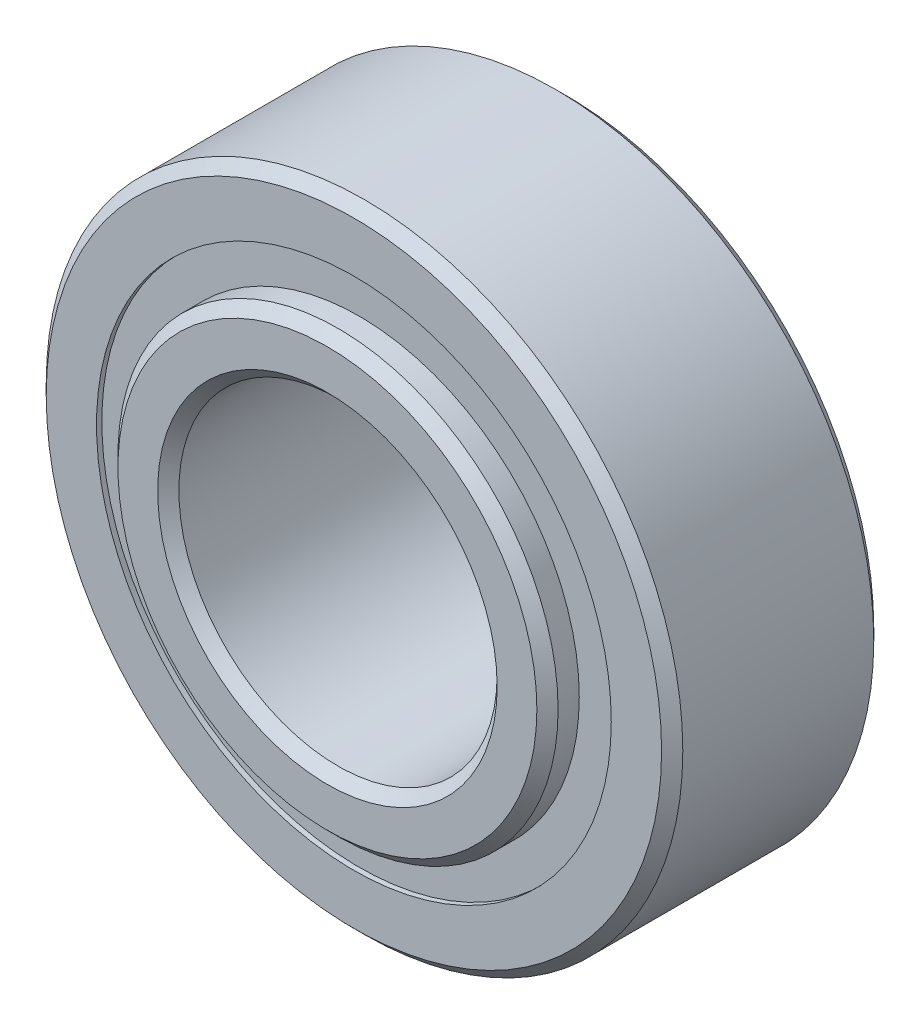
from build123d import *

# Parameters (mm, degrees)
CIRPATTERN1_COUNT = 12
SKETCH5_W         = 0.749364756
SKETCH5_H         = 0.558241758


with BuildPart() as part:
    # Sketch1 → Revolve1 (revolve)
    with BuildSketch(Plane(origin=(0, 0, 0), x_dir=(0, 0, -1), z_dir=(1, 0, 0))):
        with BuildLine():
            Line((1.42875, 4.7625), (-1.42875, 4.7625))
            Line((-1.42875, 4.7625), (-1.5875, 4.60375))
            Line((-1.5875, 4.60375), (-1.5875, 3.850995879))
            Line((-1.5875, 3.850995879), (-0.705555556, 3.850995879))
            ThreePointArc((-0.705555556, 3.850995879), (0, 4.330635244), (0.705555556, 3.850995879))
            Line((0.705555556, 3.850995879), (1.5875, 3.850995879))
            Line((1.5875, 3.850995879), (1.5875, 4.60375))
            Line((1.5875, 4.60375), (1.42875, 4.7625))
        make_face()
    revolve(axis=Axis((0, 0, 1.5875), (0, 0, -1)))


with BuildPart() as body_2:
    # Sketch3 → Revolve3 (revolve)
    with BuildSketch(Plane(origin=(0, 0, 0), x_dir=(0, 0, -1), z_dir=(1, 0, 0))):
        with BuildLine():
            Line((-1.98374, 2.54), (-1.98374, 3.134004121))
            Line((-1.98374, 3.134004121), (-1.82499, 3.292754121))
            Line((-1.82499, 3.292754121), (-0.705555556, 3.292754121))
            ThreePointArc((-0.705555556, 3.292754121), (0, 2.813114756), (0.705555556, 3.292754121))
            Line((0.705555556, 3.292754121), (1.82499, 3.292754121))
            Line((1.82499, 3.292754121), (1.98374, 3.134004121))
            Line((1.98374, 3.134004121), (1.98374, 2.54))
            Line((1.98374, 2.54), (1.82499, 2.38125))
            Line((1.82499, 2.38125), (-1.82499, 2.38125))
            Line((-1.82499, 2.38125), (-1.98374, 2.54))
        make_face()
    revolve(axis=Axis((0, 0, 1.5875), (0, 0, -1)))


with BuildPart() as body_3:
    # Sketch4 → Revolve4 (revolve)
    with BuildSketch(Plane(origin=(0, 0, 0), x_dir=(0, 0, -1), z_dir=(1, 0, 0))):
        with BuildLine():
            Line((-0.758760244, 3.571875), (0.758760244, 3.571875))
            ThreePointArc((0.758760244, 3.571875), (0, 4.330635244), (-0.758760244, 3.571875))
        make_face()
    revolve(axis=Axis((0, 3.571875, 0.758760244), (0, 0, -1)))


with BuildPart() as cirpattern1_1:
    # CirPattern1: pattern copy
    add(body_3.part.rotate(Axis((0, 0, -1.5875), (0, 0, 1)), 1 * 360 / CIRPATTERN1_COUNT))


with BuildPart() as cirpattern1_2:
    # CirPattern1: pattern copy
    add(body_3.part.rotate(Axis((0, 0, -1.5875), (0, 0, 1)), 2 * 360 / CIRPATTERN1_COUNT))


with BuildPart() as cirpattern1_3:
    # CirPattern1: pattern copy
    add(body_3.part.rotate(Axis((0, 0, -1.5875), (0, 0, 1)), 3 * 360 / CIRPATTERN1_COUNT))


with BuildPart() as cirpattern1_4:
    # CirPattern1: pattern copy
    add(body_3.part.rotate(Axis((0, 0, -1.5875), (0, 0, 1)), 4 * 360 / CIRPATTERN1_COUNT))


with BuildPart() as cirpattern1_5:
    # CirPattern1: pattern copy
    add(body_3.part.rotate(Axis((0, 0, -1.5875), (0, 0, 1)), 5 * 360 / CIRPATTERN1_COUNT))


with BuildPart() as cirpattern1_6:
    # CirPattern1: pattern copy
    add(body_3.part.rotate(Axis((0, 0, -1.5875), (0, 0, 1)), 6 * 360 / CIRPATTERN1_COUNT))


with BuildPart() as cirpattern1_7:
    # CirPattern1: pattern copy
    add(body_3.part.rotate(Axis((0, 0, -1.5875), (0, 0, 1)), 7 * 360 / CIRPATTERN1_COUNT))


with BuildPart() as cirpattern1_8:
    # CirPattern1: pattern copy
    add(body_3.part.rotate(Axis((0, 0, -1.5875), (0, 0, 1)), 8 * 360 / CIRPATTERN1_COUNT))


with BuildPart() as cirpattern1_9:
    # CirPattern1: pattern copy
    add(body_3.part.rotate(Axis((0, 0, -1.5875), (0, 0, 1)), 9 * 360 / CIRPATTERN1_COUNT))


with BuildPart() as cirpattern1_10:
    # CirPattern1: pattern copy
    add(body_3.part.rotate(Axis((0, 0, -1.5875), (0, 0, 1)), 10 * 360 / CIRPATTERN1_COUNT))


with BuildPart() as cirpattern1_11:
    # CirPattern1: pattern copy
    add(body_3.part.rotate(Axis((0, 0, -1.5875), (0, 0, 1)), 11 * 360 / CIRPATTERN1_COUNT))


with BuildPart() as body_15:
    # Sketch5 → Revolve5 (revolve)
    with BuildSketch(Plane(origin=(0, 0, 0), x_dir=(0, 0, -1), z_dir=(1, 0, 0))):
        with Locations((-1.133442622, 3.571875)):
            Rectangle(SKETCH5_W, SKETCH5_H)
        with Locations((1.133442622, 3.571875)):
            Rectangle(SKETCH5_W, SKETCH5_H)
    revolve(axis=Axis((0, 0, 1.5875), (0, 0, -1)))


solid = Compound([part.part, body_2.part, body_3.part, cirpattern1_1.part, cirpattern1_2.part, cirpattern1_3.part, cirpattern1_4.part, cirpattern1_5.part, cirpattern1_6.part, cirpattern1_7.part, cirpattern1_8.part, cirpattern1_9.part, cirpattern1_10.part, cirpattern1_11.part, body_15.part])
